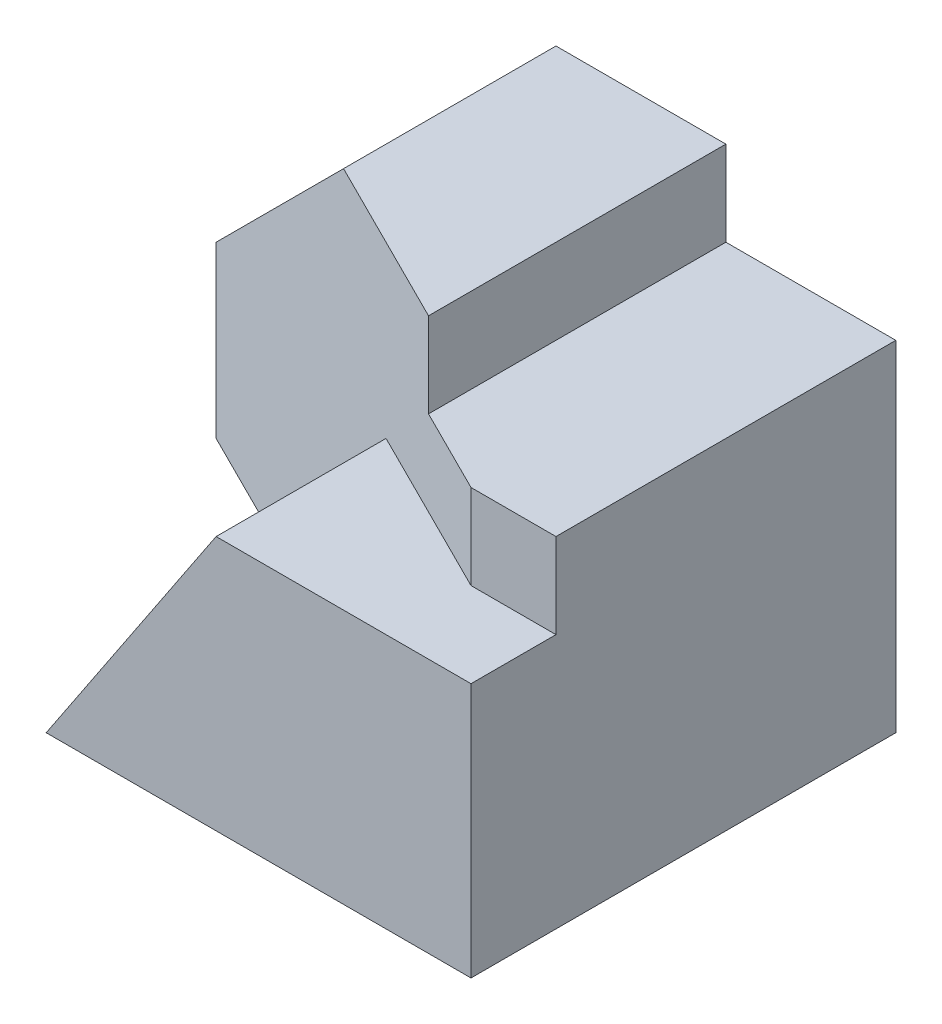
from build123d import *

# Parameters (mm, degrees)
SKETCH1_W           = 70
SKETCH1_H           = 50
BOSS_EXTRUDE1_DEPTH = 50
SKETCH2_W           = 20
SKETCH2_H           = 10
CUT_EXTRUDE1_DEPTH  = 50
CUT_EXTRUDE2_DEPTH  = 50
CUT_EXTRUDE3_DEPTH  = 30
SKETCH6_W           = 10
SKETCH6_H           = 10
CUT_EXTRUDE4_DEPTH  = 10
BOSS_EXTRUDE2_DEPTH = 10
CUT_EXTRUDE5_DEPTH  = 10
BOSS_EXTRUDE3_DEPTH = 10
BOSS_EXTRUDE4_DEPTH = 10
BOSS_EXTRUDE5_DEPTH = 10
BOSS_EXTRUDE6_DEPTH = 22


with BuildPart() as part:
    # Sketch1 → Boss-Extrude1 (new body)
    with BuildSketch(Plane.XY):
        with Locations((35, 25)):
            Rectangle(SKETCH1_W, SKETCH1_H)
    extrude(amount=BOSS_EXTRUDE1_DEPTH)

    # Sketch2 → Cut-Extrude1 (cut)
    with BuildSketch(Plane.XY.offset(50)):
        Polygon((0, 20), (30, 50), (0, 50), align=None)
        with Locations((60, 45)):
            Rectangle(SKETCH2_W, SKETCH2_H)
    extrude(amount=-CUT_EXTRUDE1_DEPTH, mode=Mode.SUBTRACT)

    # Sketch3 → Cut-Extrude2 (cut)
    with BuildSketch(Plane.XZ):
        Polygon((0, 10), (20, 20), (20, 50), (0, 50), align=None)
    extrude(amount=-CUT_EXTRUDE2_DEPTH, mode=Mode.SUBTRACT)

    # Sketch5 → Cut-Extrude3 (cut)
    with BuildSketch(Plane.XY.offset(50)):
        Polygon((20, 0), (40, 30), (60, 30), (60, 40), (50, 40), (50, 50), (30, 50), (20, 40), align=None)
    extrude(amount=-CUT_EXTRUDE3_DEPTH, mode=Mode.SUBTRACT)

    # Sketch6 → Cut-Extrude4 (cut)
    with BuildSketch(Plane.XY.offset(50)):
        with Locations((65, 35)):
            Rectangle(SKETCH6_W, SKETCH6_H)
    extrude(amount=-CUT_EXTRUDE4_DEPTH, mode=Mode.SUBTRACT)

    # Sketch7 → Boss-Extrude2 (add)
    with BuildSketch(Plane(origin=(0, 40, 0), x_dir=(1, 0, 0), z_dir=(0, 1, 0))):
        Polygon((60, -40), (0, -10), (60, -10), (60, -20), align=None)
    extrude(amount=-BOSS_EXTRUDE2_DEPTH)

    # Sketch8 → Cut-Extrude5 (cut)
    with BuildSketch(Plane(origin=(0, 0, 10), x_dir=(-1, 0, 0), z_dir=(0, 0, -1))):
        Polygon((0, 30), (-10, 30), (-20, 40), (0, 40), align=None)
    extrude(amount=-CUT_EXTRUDE5_DEPTH, mode=Mode.SUBTRACT)

    # Sketch9 → Boss-Extrude3 (add)
    with BuildSketch(Plane(origin=(0, 40, 0), x_dir=(1, 0, 0), z_dir=(0, 1, 0))):
        Polygon((30, -25), (50, -35), (50, -20), (30, -20), align=None)
    extrude(amount=BOSS_EXTRUDE3_DEPTH)

    # Sketch10 → Boss-Extrude4 (add)
    with BuildSketch(Plane(origin=(-4, 0, 8), x_dir=(0.894427191, 0, 0.447213595), z_dir=(-0.447213595, 0, 0.894427191))):
        Polygon((26.83281573, 40), (38.013155617, 50), (38.013155617, 40), align=None)
    extrude(amount=-BOSS_EXTRUDE4_DEPTH)

    # Sketch11 → Boss-Extrude5 (add)
    with BuildSketch(Plane(origin=(-10, 10, 0), x_dir=(0, 0, 1), z_dir=(-0.707106781, 0.707106781, 0))):
        Polygon((20, 42.426406871), (20, 56.568542495), (25, 56.568542495), align=None)
    extrude(amount=-BOSS_EXTRUDE5_DEPTH)

    # Sketch12 → Boss-Extrude6 (add)
    with BuildSketch(Plane(origin=(-4, 0, 8), x_dir=(0.894427191, 0, 0.447213595), z_dir=(-0.447213595, 0, 0.894427191))):
        Polygon((26.83281573, 0), (26.83281573, 30), (49.193495505, 30), align=None)
    extrude(amount=-BOSS_EXTRUDE6_DEPTH)


solid = part.part
